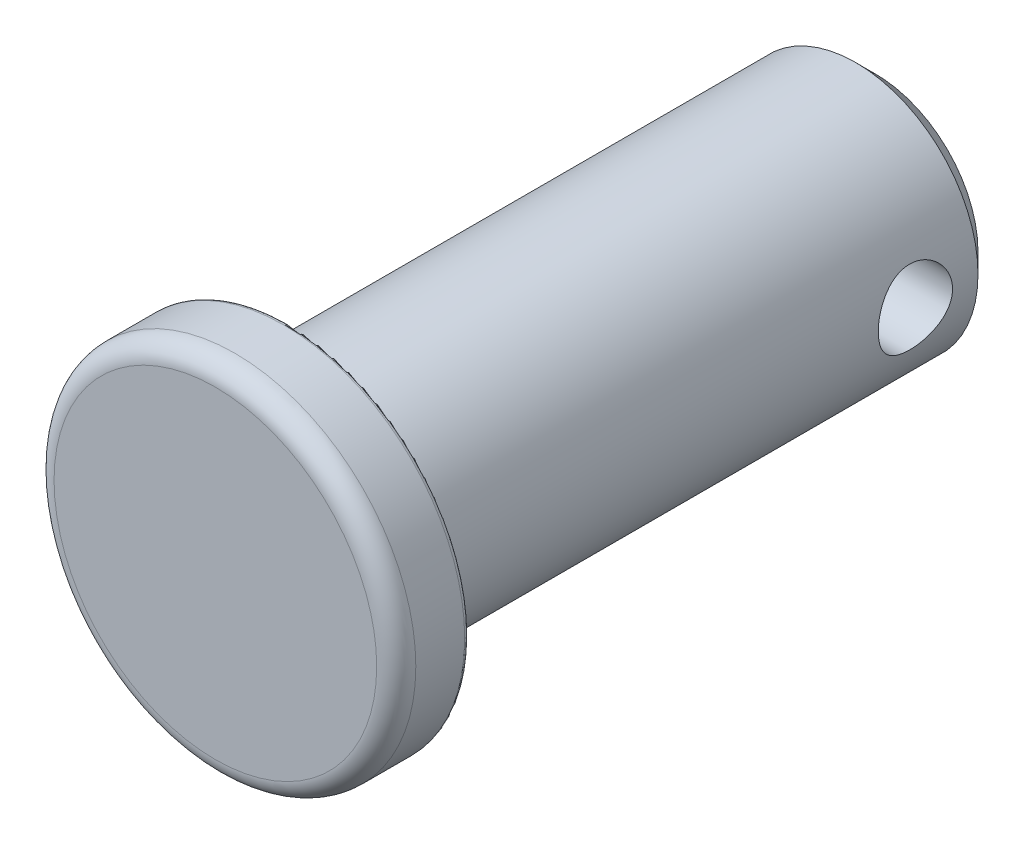
from build123d import *

# Parameters (mm, degrees)
SKETCH2_R           = 0.9652
EXTRUDE1_DEPTH      = 5.699
EXTRUDE1_DEPTH_BACK = 5.6990001


with BuildPart() as part:
    # Sketch1 → Revolve Base (revolve)
    with BuildSketch(Plane(origin=(0, 0, 0), x_dir=(0, 0, -1), z_dir=(1, 0, 0))):
        with BuildLine():
            Line((0, 0), (0, 4.191))
            ThreePointArc((0, 4.191), (0.148789755, 4.550210245), (0.508, 4.699))
            Line((0.508, 4.699), (1.778, 4.699))
            ThreePointArc((1.778, 4.699), (1.867802561, 4.661802561), (1.905, 4.572))
            Line((1.905, 4.572), (1.905, 3.175))
            Line((1.905, 3.175), (16.637, 3.175))
            Line((16.637, 3.175), (17.145, 2.667))
            Line((17.145, 2.667), (17.145, 0))
            Line((17.145, 0), (0, 0))
        make_face()
    revolve(axis=Axis((0, 0, 0), (0, 0, -1)))

    # Sketch2 → Extrude1 (cut, two sides)
    with BuildSketch(Plane(origin=(0, 0, 0), x_dir=(0, 0, -1), z_dir=(1, 0, 0))) as extrude1_sk:
        with Locations((15.0114, 0)):
            Circle(SKETCH2_R)
    extrude(amount=EXTRUDE1_DEPTH, mode=Mode.SUBTRACT)
    extrude(extrude1_sk.sketch, amount=-EXTRUDE1_DEPTH_BACK, mode=Mode.SUBTRACT)


solid = part.part
